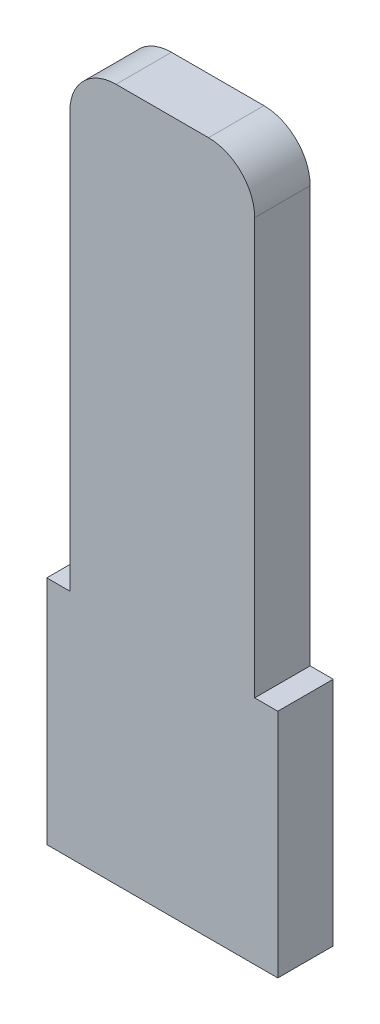
from build123d import *

# Parameters (mm, degrees)
AUFSATZ_LINEAR_AUSTRAGEN1_DEPTH = 0.6
VERRUNDUNG1_R                   = 1
VERRUNDUNG2_R                   = 1


with BuildPart() as part:
    # glider-sketch → Aufsatz-Linear austragen1 (new body, symmetric)
    with BuildSketch(Plane.XY):
        Polygon((-2.5, 2.5), (-2, 2.5), (-2, 12.5), (2, 12.5), (2, 2.5), (2.5, 2.5), (2.5, -2.5), (-2.5, -2.5), align=None)
    extrude(amount=AUFSATZ_LINEAR_AUSTRAGEN1_DEPTH, both=True)

    # Verrundung1
    verrundung1_edges = [part.edges().sort_by_distance(p)[0] for p in [
        (2, 12.5, 0),
    ]]
    fillet(verrundung1_edges, radius=VERRUNDUNG1_R)

    # Verrundung2
    verrundung2_edges = [part.edges().sort_by_distance(p)[0] for p in [
        (-2, 12.5, 0),
    ]]
    fillet(verrundung2_edges, radius=VERRUNDUNG2_R)


solid = part.part
